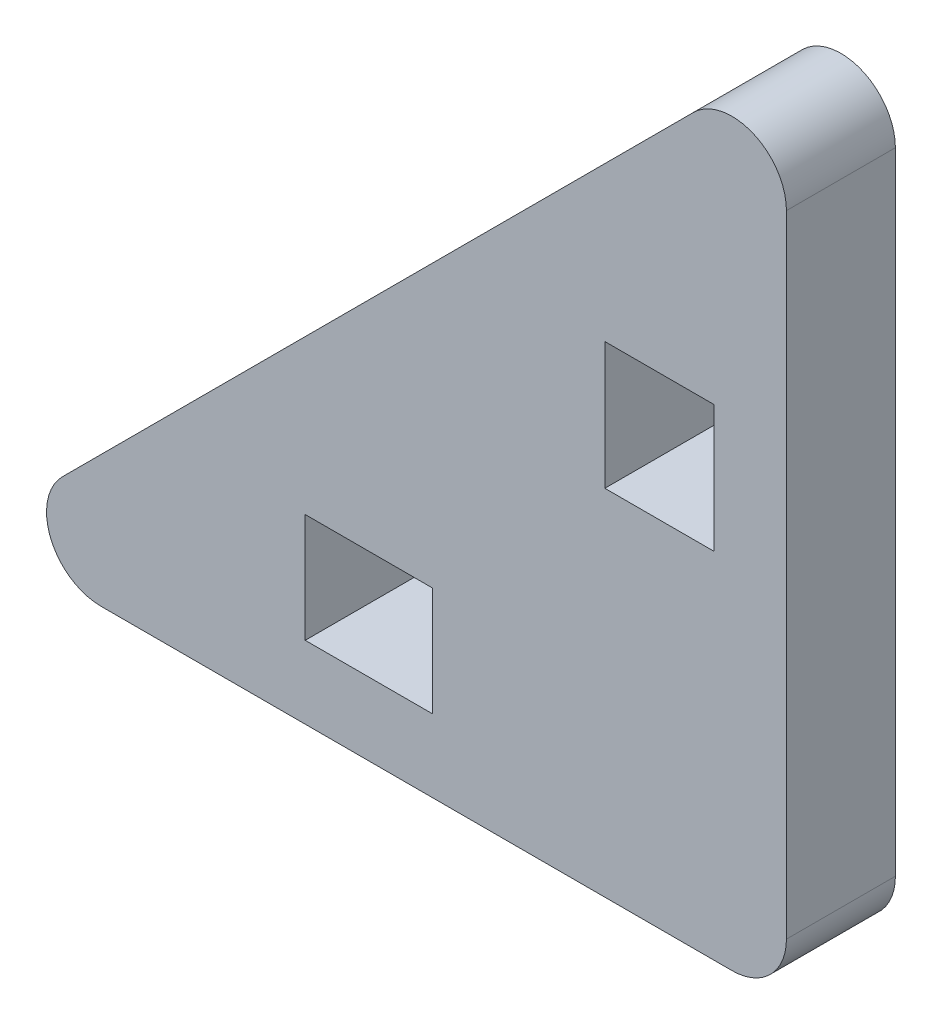
from build123d import *

# Parameters (mm, degrees)
SKETCH_1_W      = 3.5
SKETCH_1_H      = 3
SKETCH_1_W_2    = 3
SKETCH_1_H_2    = 3.5
EXTRUDE_1_DEPTH = 3
FILLET_1_R      = 1.5


with BuildPart() as part:
    # Эскиз1 → Бобышка-Вытянуть1 (new body)
    with BuildSketch(Plane.XY):
        Polygon((0, 22.492640687), (0, 0), (-22.492640687, 0), align=None)
        with Locations((-11.5, 3.5)):
            Rectangle(SKETCH_1_W, SKETCH_1_H, mode=Mode.SUBTRACT)
        with Locations((-3.5, 11.5)):
            Rectangle(SKETCH_1_W_2, SKETCH_1_H_2, mode=Mode.SUBTRACT)
    extrude(amount=EXTRUDE_1_DEPTH)

    # Скругление1
    fillet_1_edges = [part.edges().sort_by_distance(p)[0] for p in [
        (0, 0, 1.5),
        (-22.492640687, 0, 1.5),
        (0, 22.492640687, 1.5),
    ]]
    fillet(fillet_1_edges, radius=FILLET_1_R)


solid = part.part
